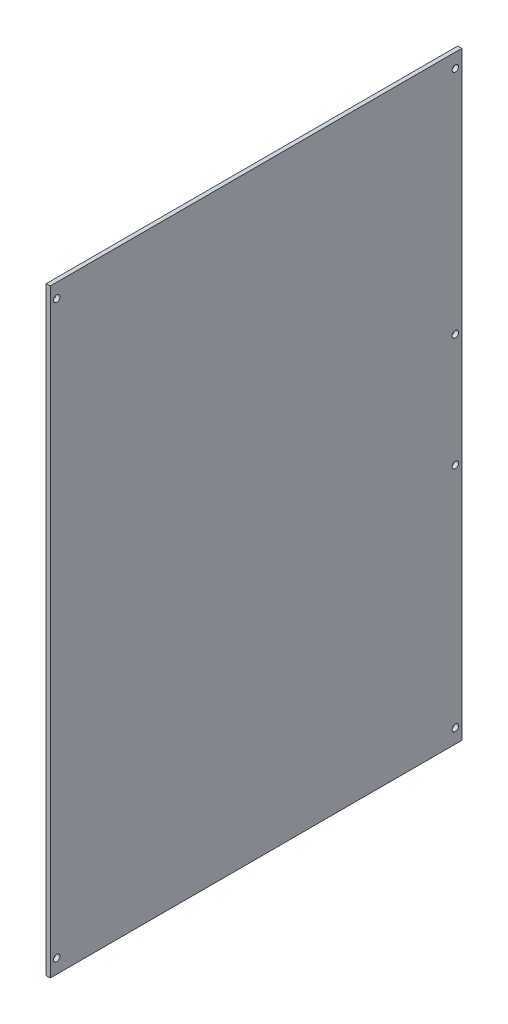
from build123d import *

# Parameters (mm, degrees)
SKETCH1_W           = 160
SKETCH1_H           = 233
SKETCH1_R           = 1.25
BOSS_EXTRUDE1_DEPTH = 1.5875


with BuildPart() as part:
    # Sketch1 → Boss-Extrude1 (new body)
    with BuildSketch(Plane(origin=(0, 0, 0), x_dir=(0, 0, -1), z_dir=(1, 0, 0))):
        with Locations((80, 116.5)):
            Rectangle(SKETCH1_W, SKETCH1_H)
        with Locations((2.5, 227.5)):
            Circle(SKETCH1_R, mode=Mode.SUBTRACT)
        with Locations((157.5, 227.5)):
            Circle(SKETCH1_R, mode=Mode.SUBTRACT)
        with Locations((157.5, 5.5)):
            Circle(SKETCH1_R, mode=Mode.SUBTRACT)
        with Locations((2.5, 5.5)):
            Circle(SKETCH1_R, mode=Mode.SUBTRACT)
        with Locations((157.5, 94)):
            Circle(SKETCH1_R, mode=Mode.SUBTRACT)
        with Locations((157.5, 138)):
            Circle(SKETCH1_R, mode=Mode.SUBTRACT)
    extrude(amount=BOSS_EXTRUDE1_DEPTH)


solid = part.part
